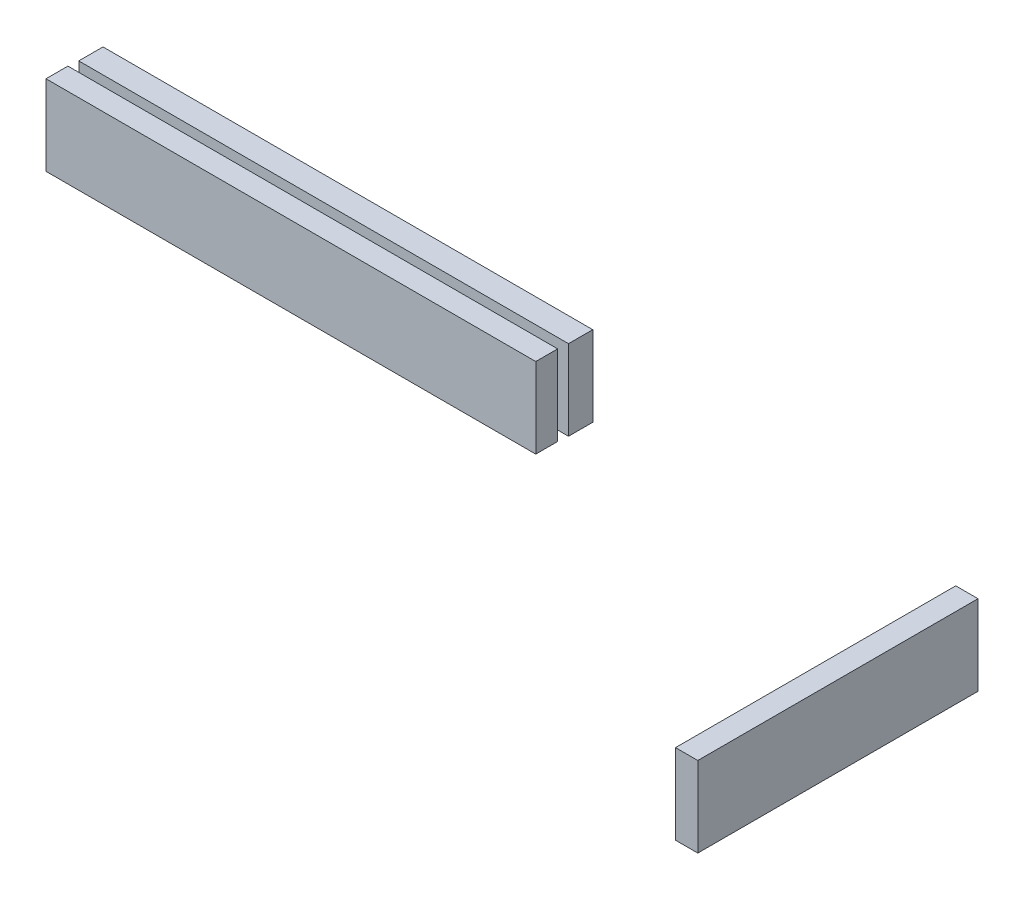
from build123d import *

# Parameters (mm, degrees)
SKETCH1_W             = 61.053444607
SKETCH1_H             = 3.022447753
BOSS_EXTRUDE1_DEPTH   = 10
SKETCH1_W_2           = 61.053444606
SKETCH1_H_2           = 2.731728324
BOSS_EXTRUDE1_2_DEPTH = 10
SKETCH1_W_3           = 2.776893353
SKETCH1_H_3           = 34.930395329
BOSS_EXTRUDE1_3_DEPTH = 10


with BuildPart() as part:
    # Sketch1 → Boss-Extrude1 (new body)
    with BuildSketch(Plane(origin=(0, 0, 0), x_dir=(1, 0, 0), z_dir=(0, 1, 0))):
        with Locations((-7.319475954, 14.668631102)):
            Rectangle(SKETCH1_W, SKETCH1_H)
    extrude(amount=BOSS_EXTRUDE1_DEPTH)


with BuildPart() as body_2:
    # Sketch1 → Boss-Extrude1 2 (new body)
    with BuildSketch(Plane(origin=(0, 0, 0), x_dir=(1, 0, 0), z_dir=(0, 1, 0))):
        with Locations((-7.433205843, 10.553839763)):
            Rectangle(SKETCH1_W_2, SKETCH1_H_2)
    extrude(amount=BOSS_EXTRUDE1_2_DEPTH)


with BuildPart() as body_3:
    # Sketch1 → Boss-Extrude1 3 (new body)
    with BuildSketch(Plane(origin=(0, 0, 0), x_dir=(1, 0, 0), z_dir=(0, 1, 0))):
        with Locations((74.876018125, -6.317453736)):
            Rectangle(SKETCH1_W_3, SKETCH1_H_3)
    extrude(amount=BOSS_EXTRUDE1_3_DEPTH)


solid = Compound([part.part, body_2.part, body_3.part])
